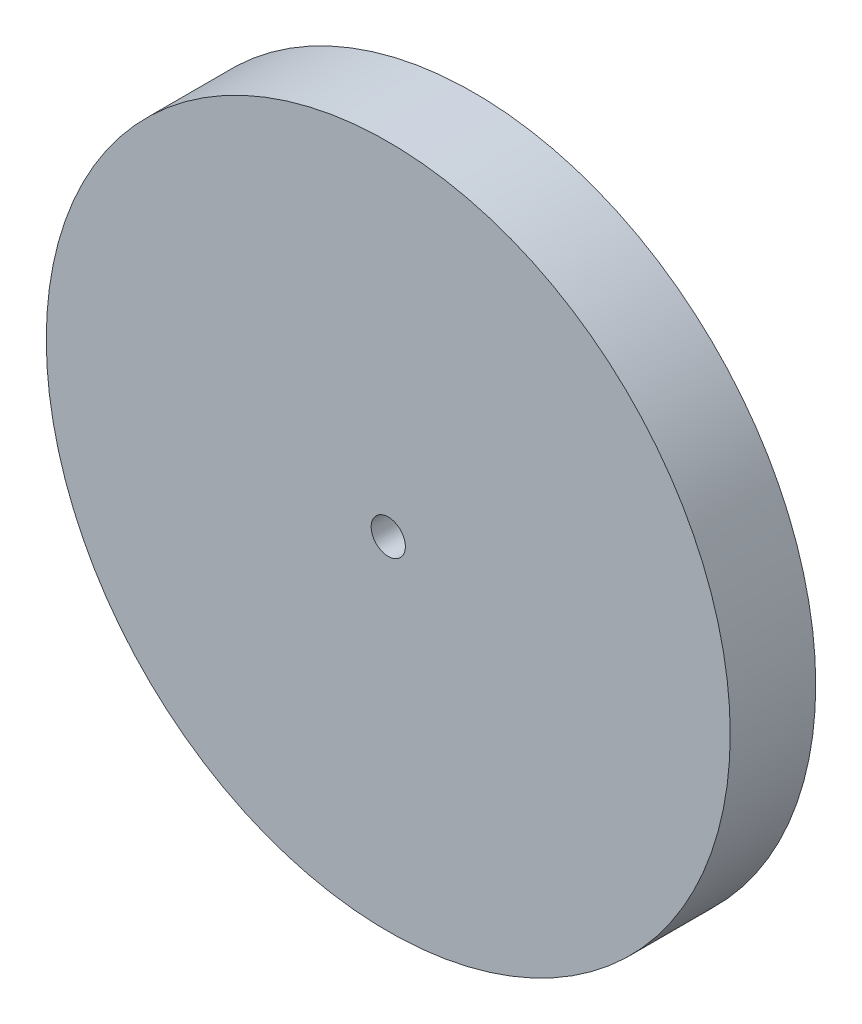
from build123d import *

# Parameters (mm, degrees)
SKETCH1_R           = 25.4
SKETCH1_R_2         = 1.27
BOSS_EXTRUDE1_DEPTH = 6.35


with BuildPart() as part:
    # Sketch1 → Boss-Extrude1 (new body)
    with BuildSketch(Plane.XY):
        with Locations((0, -25.4)):
            Circle(SKETCH1_R)
        with Locations((0, -25.4)):
            Circle(SKETCH1_R_2, mode=Mode.SUBTRACT)
    extrude(amount=BOSS_EXTRUDE1_DEPTH)


solid = part.part
